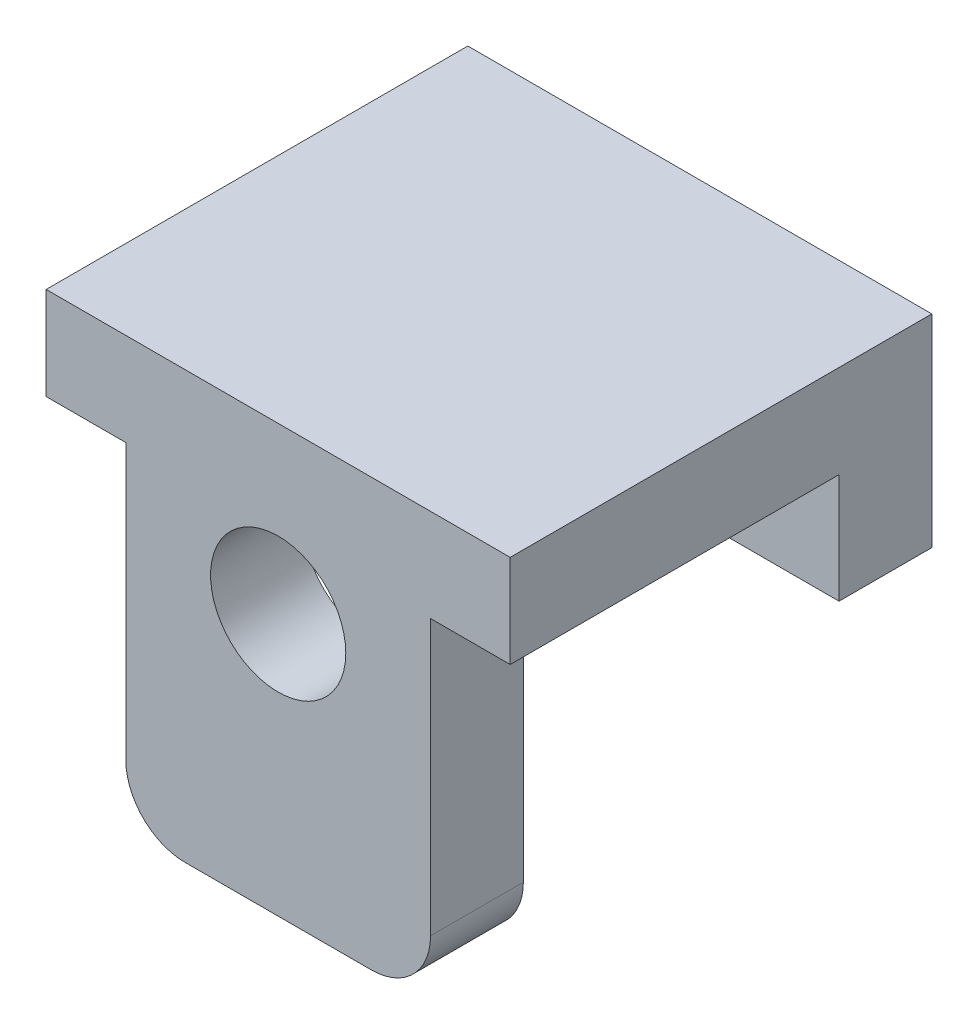
from build123d import *

# Parameters (mm, degrees)
SKETCH1_W      = 6.35
SKETCH1_H      = 2.77
EXTRUDE1_DEPTH = 1.27
SKETCH2_W      = 6.35
SKETCH2_H      = 1.27
EXTRUDE2_DEPTH = 4.5
SKETCH3_W      = 4.17
SKETCH3_H      = 4.57
SKETCH3_R      = 0.925
EXTRUDE3_DEPTH = 1.27
FILLET1_R      = 0.81


with BuildPart() as part:
    # Sketch1 → Extrude1 (new body)
    with BuildSketch(Plane.XY):
        Rectangle(SKETCH1_W, SKETCH1_H)
    extrude(amount=EXTRUDE1_DEPTH)

    # Sketch2 → Extrude2 (add)
    with BuildSketch(Plane.XY.offset(1.27)):
        with Locations((0, 0.75)):
            Rectangle(SKETCH2_W, SKETCH2_H)
    extrude(amount=EXTRUDE2_DEPTH)

    # Sketch3 → Extrude3 (add)
    with BuildSketch(Plane.XY.offset(5.77)):
        with Locations((0, -2.17)):
            Rectangle(SKETCH3_W, SKETCH3_H)
        with Locations((0, -0.875)):
            Circle(SKETCH3_R, mode=Mode.SUBTRACT)
    extrude(amount=-EXTRUDE3_DEPTH)

    # Fillet1
    fillet1_edges = [part.edges().sort_by_distance(p)[0] for p in [
        (-2.085, -4.455, 5.135),
        (2.085, -4.455, 5.135),
    ]]
    fillet(fillet1_edges, radius=FILLET1_R)


solid = part.part
